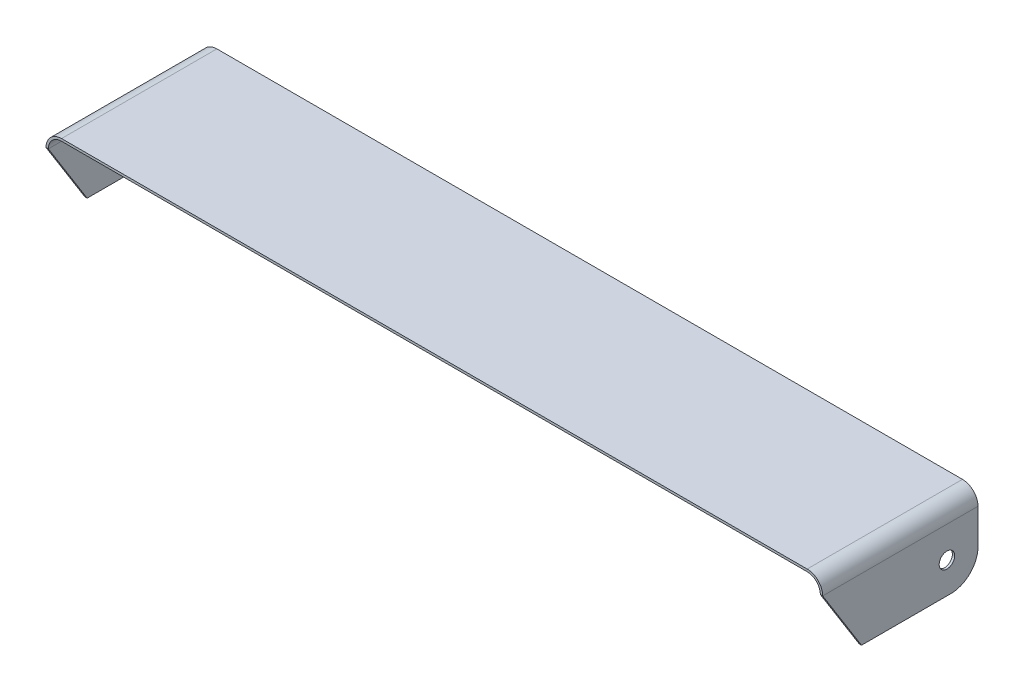
from build123d import *

# Parameters (mm, degrees)
BOSS_EXTRUDE1_DEPTH = 100
CUT_EXTRUDE1_DEPTH  = 1001
SKETCH3_R           = 10
CUT_EXTRUDE2_DEPTH  = 1001
FILLET1_R           = 35


with BuildPart() as part:
    # Sketch1 → Boss-Extrude1 (new body, symmetric)
    with BuildSketch(Plane.XY):
        with BuildLine():
            Line((-500, 0), (-500, 80))
            ThreePointArc((-500, 80), (-494.142135624, 94.142135624), (-480, 100))
            Line((-480, 100), (480, 100))
            ThreePointArc((480, 100), (494.142135624, 94.142135624), (500, 80))
            Line((500, 80), (500, 0))
            Line((500, 0), (497, 0))
            Line((497, 0), (497, 80))
            ThreePointArc((497, 80), (492.02081528, 92.02081528), (480, 97))
            Line((480, 97), (-480, 97))
            ThreePointArc((-480, 97), (-492.02081528, 92.02081528), (-497, 80))
            Line((-497, 80), (-497, 0))
            Line((-497, 0), (-500, 0))
        make_face()
    extrude(amount=BOSS_EXTRUDE1_DEPTH, both=True)

    # Sketch2 → Cut-Extrude1 (cut, through all)
    with BuildSketch(Plane(origin=(500, 0, 0), x_dir=(0, 0, -1), z_dir=(1, 0, 0))):
        Polygon((-100, 80), (-100, 0), (-50, 0), align=None)
    extrude(amount=-CUT_EXTRUDE1_DEPTH, mode=Mode.SUBTRACT)

    # Sketch3 → Cut-Extrude2 (cut, through all)
    with BuildSketch(Plane(origin=(500, 0, 0), x_dir=(0, 0, -1), z_dir=(1, 0, 0))):
        with Locations((60, 40)):
            Circle(SKETCH3_R)
    extrude(amount=-CUT_EXTRUDE2_DEPTH, mode=Mode.SUBTRACT)

    # Fillet1
    fillet1_edges = [part.edges().sort_by_distance(p)[0] for p in [
        (498.5, 0, -100),
        (-498.5, 0, -100),
    ]]
    fillet(fillet1_edges, radius=FILLET1_R)


solid = part.part
